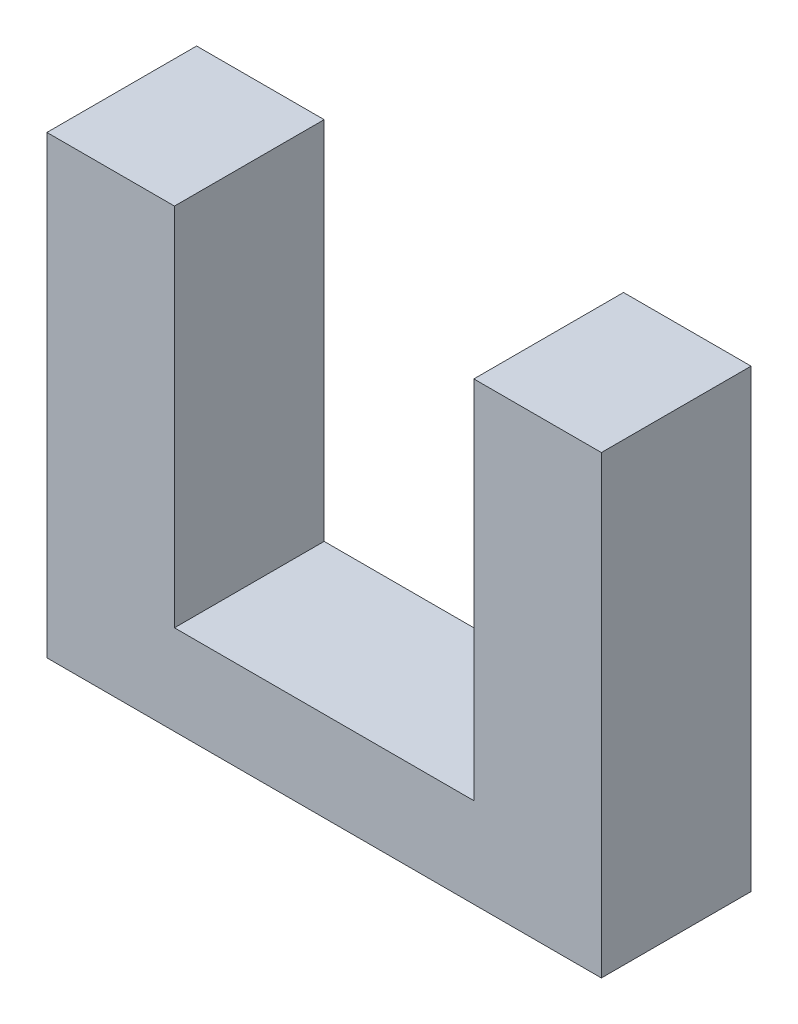
from build123d import *

# Parameters (mm, degrees)
BOSS_EXTRUDE1_DEPTH = 2.5
SKETCH2_R           = 0.715
BOSS_EXTRUDE2_DEPTH = 1.3


with BuildPart() as part:
    # Sketch1 → Boss-Extrude1 (new body, symmetric)
    with BuildSketch(Plane.XY):
        Polygon((-9.26, -3), (-9.26, 12.2), (-5, 12.2), (-5, 0), (5, 0), (5, 12.2), (9.26, 12.2), (9.26, -3), align=None)
    extrude(amount=BOSS_EXTRUDE1_DEPTH, both=True)

    # Sketch2 → Boss-Extrude2 (add)
    with BuildSketch(Plane.XZ.offset(3)):
        Circle(SKETCH2_R)
    extrude(amount=BOSS_EXTRUDE2_DEPTH)


solid = part.part
